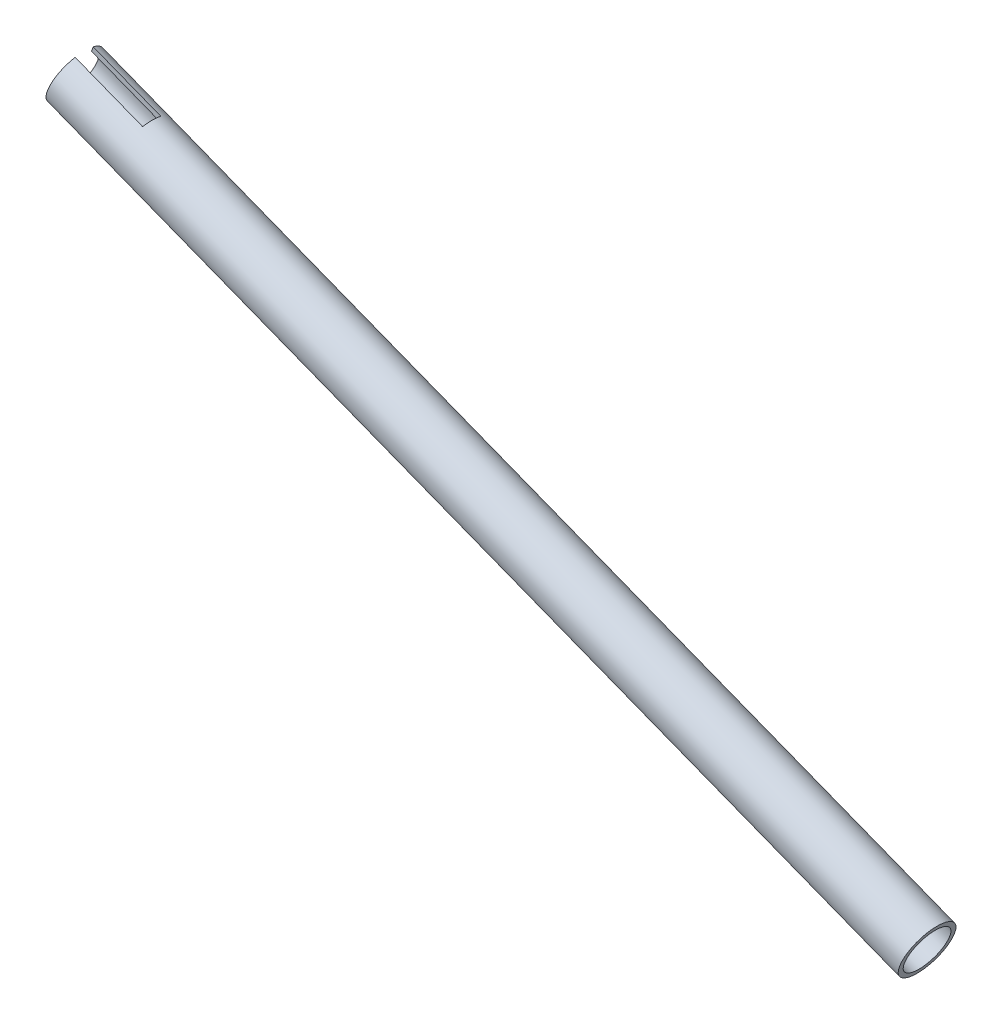
from build123d import *

# Parameters (mm, degrees)
CUT_EXTRUDE1_START = -3.175
CUT_EXTRUDE1_DEPTH = 6.35


with BuildPart() as part:
    # Sketch1 → Revolve1 (revolve)
    with BuildSketch(Plane.XY):
        Polygon((-290.013124818, -141.869021758), (-290.612556192, -143.407359506), (-589.391523341, -26.984625229), (-588.792091967, -25.446287481), align=None)
    revolve(axis=Axis((-469.305066075, -63.555147651, 0), (-0.931761204, 0.363071699, 0)))

    # Sketch2 → Cut-Extrude1 (cut)
    with BuildSketch(Plane.XY.offset(CUT_EXTRUDE1_START)):
        Polygon((-558.808272896, -18.456595432), (-565.724788753, -36.206646372), (-589.391523341, -26.984625229), (-582.475007484, -9.234574289), align=None)
    extrude(amount=CUT_EXTRUDE1_DEPTH, mode=Mode.SUBTRACT)


solid = part.part
